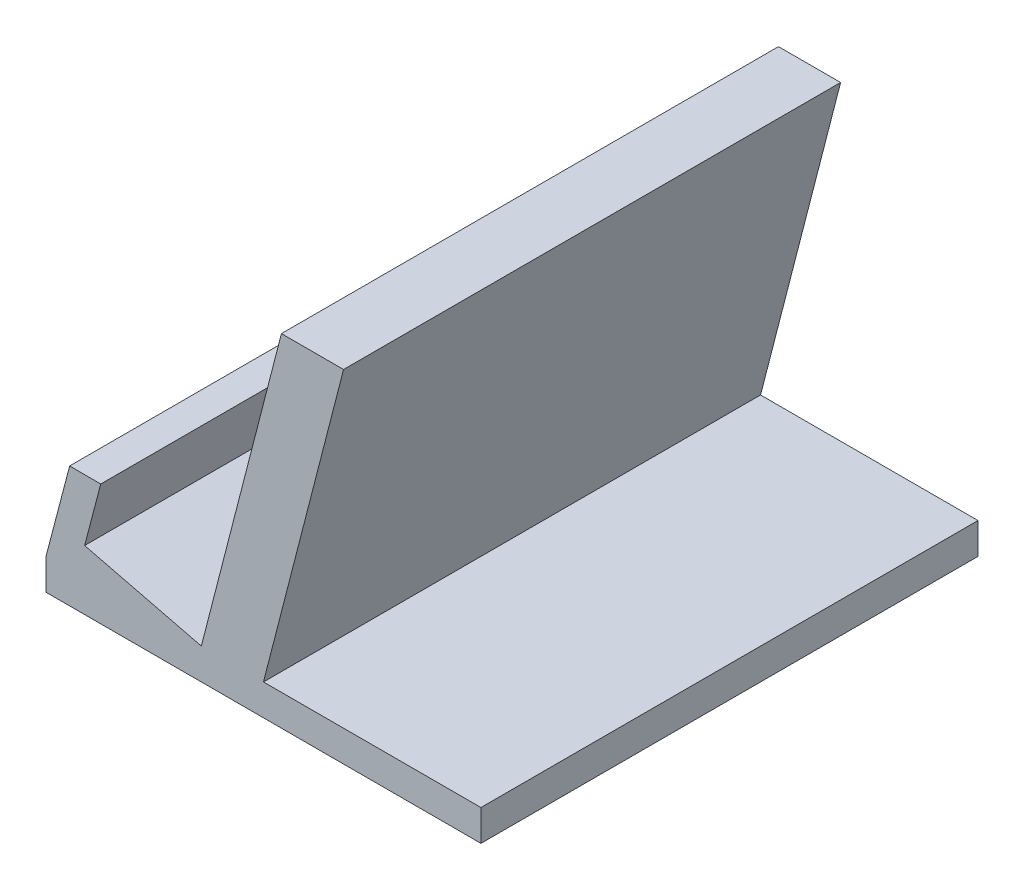
from build123d import *

# Parameters (mm, degrees)
EXTRUDE_4_DEPTH = 80


with BuildPart() as part:
    # 草圖1 → 填料-伸長4 (new body)
    with BuildSketch(Plane.XY):
        Polygon((-0.045443236, -0.270925117), (-10.045443236, -0.270925117), (-35.045443236, -0.270925117), (-35.045443236, -5.270925117), (34.954556764, -5.270925117), (34.954556764, -0.270925117), align=None)
        Polygon((2.843781018, 49.729074883), (-10.045443236, -0.270925117), (-0.045443236, -0.270925117), (12.843781018, 49.729074883), align=None)
        Polygon((-35.045443236, -0.270925117), (-10.045443236, -0.270925117), (-28.827398823, 4.355440349), (-26.239696609, 14.22289864), (-31.239662656, 14.241324755), align=None)
    extrude(amount=EXTRUDE_4_DEPTH)


solid = part.part
